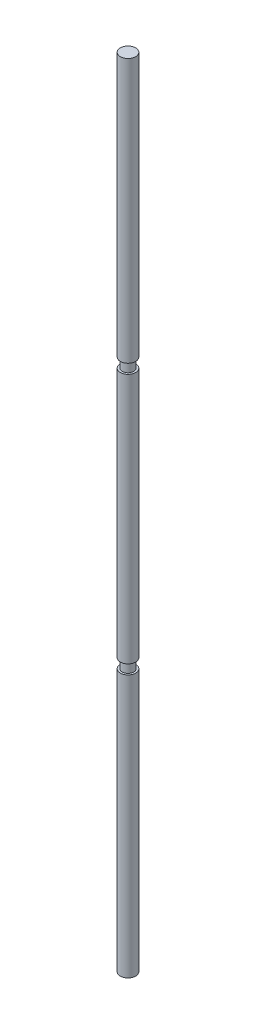
from build123d import *

# Parameters (mm, degrees)
SKETCH1_R           = 3.175
BOSS_EXTRUDE1_DEPTH = 330.2
SKETCH2_R           = 3.4925
SKETCH2_R_2         = 2.38125
CUT_EXTRUDE1_DEPTH  = 3.96875
LPATTERN1_COUNT     = 2
LPATTERN1_PITCH     = 107.95


with BuildPart() as part:
    # Sketch1 → Boss-Extrude1 (new body)
    with BuildSketch(Plane(origin=(0, 0, 0), x_dir=(1, 0, 0), z_dir=(0, 1, 0))):
        with Locations(Location((0, 0, 0), (0, 0, 270))):  # turned: the seam where the file's is
            Circle(SKETCH1_R)
    extrude(amount=BOSS_EXTRUDE1_DEPTH)

    # Sketch2 → Cut-Extrude1 (cut)
    with BuildSketch(Plane(origin=(0, 108.83011, 0), x_dir=(-1, 0, 0), z_dir=(0, 1, 0))):
        Circle(SKETCH2_R)
        with Locations(Location((0, 0, 0), (0, 0, 90))):  # turned: the seam where the file's is
            Circle(SKETCH2_R_2, mode=Mode.SUBTRACT)
    cut_extrude1 = extrude(amount=CUT_EXTRUDE1_DEPTH, mode=Mode.SUBTRACT)

    # LPattern1: Cut-Extrude1 ×2
    with Locations(*[(0, i * LPATTERN1_PITCH, 0) for i in range(1, LPATTERN1_COUNT)]):
        add(cut_extrude1, mode=Mode.SUBTRACT)


solid = part.part
